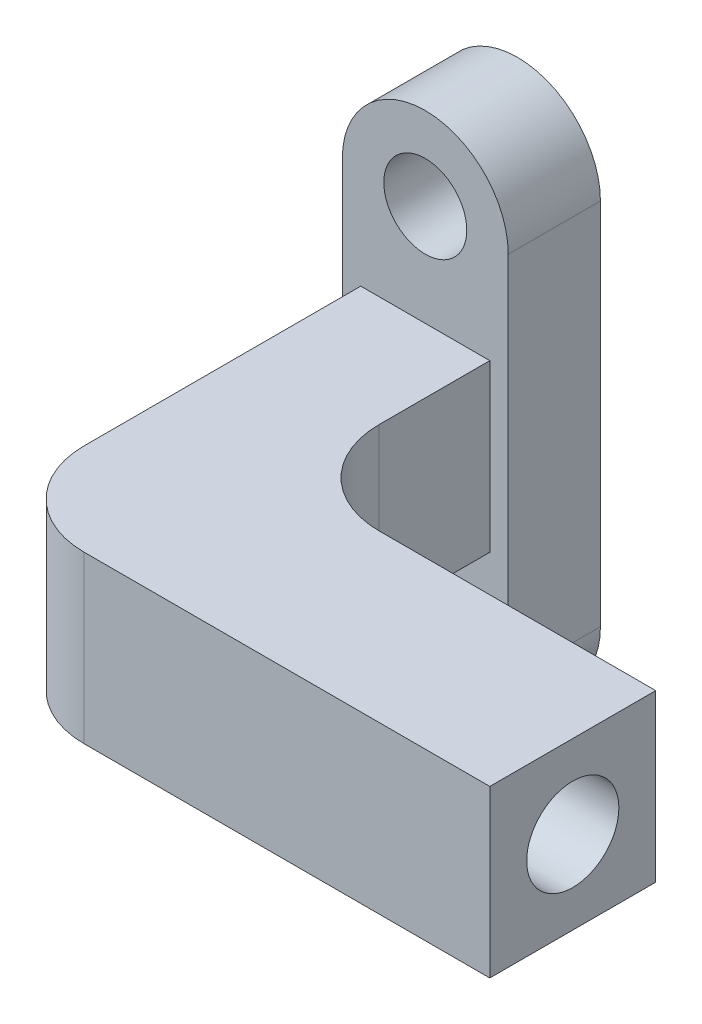
from build123d import *

# Parameters (mm, degrees)
SKETCH1_R           = 2.25
BOSS_EXTRUDE1_DEPTH = 5
SKETCH2_W           = 7
SKETCH2_H           = 9
BOSS_EXTRUDE2_DEPTH = 20
SKETCH4_W           = 9
SKETCH4_H           = 9
BOSS_EXTRUDE4_DEPTH = 20
SKETCH5_R           = 2.5
CUT_EXTRUDE1_DEPTH  = 25
FILLET1_R           = 5
FILLET2_R           = 5


with BuildPart() as part:
    # Sketch1 → Boss-Extrude1 (new body)
    with BuildSketch(Plane.XY):
        with BuildLine():
            ThreePointArc((4.5, 10), (0, 14.5), (-4.5, 10))
            Line((-4.5, 10), (-4.5, -10))
            ThreePointArc((-4.5, -10), (0, -14.5), (4.5, -10))
            Line((4.5, -10), (4.5, 10))
        make_face()
        with Locations((0, 10)):
            Circle(SKETCH1_R, mode=Mode.SUBTRACT)
        with Locations((0, -10)):
            Circle(SKETCH1_R, mode=Mode.SUBTRACT)
    extrude(amount=BOSS_EXTRUDE1_DEPTH)

    # Sketch2 → Boss-Extrude2 (add)
    with BuildSketch(Plane.XY.offset(5)):
        Rectangle(SKETCH2_W, SKETCH2_H)
    extrude(amount=BOSS_EXTRUDE2_DEPTH)

    # Sketch4 → Boss-Extrude4 (add)
    with BuildSketch(Plane(origin=(3.5, 0, 0), x_dir=(0, 0, -1), z_dir=(1, 0, 0))):
        with Locations((-20.5, 0)):
            Rectangle(SKETCH4_W, SKETCH4_H)
    extrude(amount=BOSS_EXTRUDE4_DEPTH)

    # Sketch5 → Cut-Extrude1 (cut)
    with BuildSketch(Plane(origin=(23.5, 0, 0), x_dir=(0, 0, -1), z_dir=(1, 0, 0))):
        with Locations((-20.5, 0)):
            Circle(SKETCH5_R)
    extrude(amount=-CUT_EXTRUDE1_DEPTH, mode=Mode.SUBTRACT)

    # Fillet1
    fillet1_edges = [part.edges().sort_by_distance(p)[0] for p in [
        (3.5, 0, 16),
    ]]
    fillet(fillet1_edges, radius=FILLET1_R)

    # Fillet2
    fillet2_edges = [part.edges().sort_by_distance(p)[0] for p in [
        (-3.5, 0, 25),
    ]]
    fillet(fillet2_edges, radius=FILLET2_R)


solid = part.part
